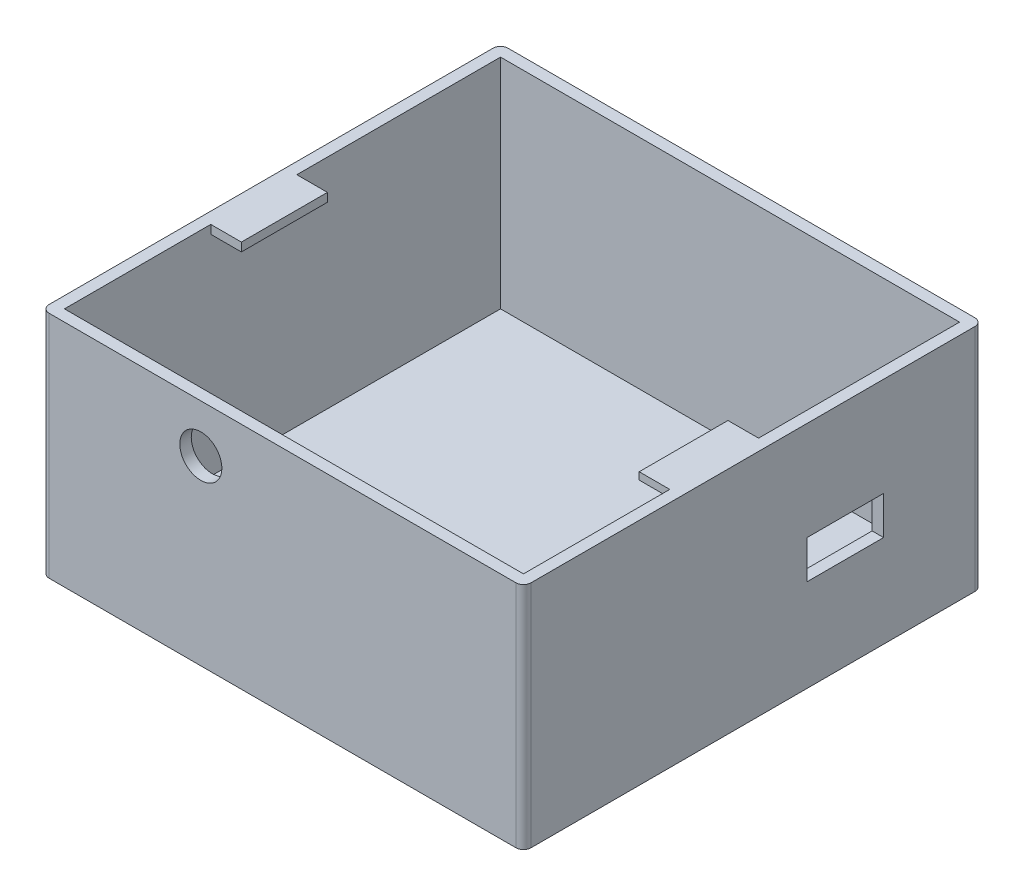
from build123d import *

# Parameters (mm, degrees)
SKETCH1_W               = 63
SKETCH1_H               = 60
BOSS_EXTRUDE1_DEPTH     = 30
SKETCH2_W               = 60
SKETCH2_H               = 57
CUT_EXTRUDE1_DEPTH      = 44
FILLET5_R               = 1
FILLET6_R               = 1
SKETCH4_W               = 11.2479448
SKETCH4_H               = 1.120832932
BOSS_EXTRUDE2_DEPTH     = 4
SKETCH7_W               = 11.602367515
SKETCH7_H               = 0.946433532
BOSS_EXTRUDE3_DEPTH     = 4
SKETCH13_W              = 60
SKETCH13_H              = 1.5
BOSS_EXTRUDE4_DEPTH     = 52
SKETCH8_R               = 2.75
CUT_EXTRUDE2_DEPTH      = 15
CUT_EXTRUDE2_DEPTH_BACK = 20
SKETCH18_W              = 10
SKETCH18_H              = 5
CUT_EXTRUDE4_DEPTH      = 15


with BuildPart() as part:
    # Sketch1 → Boss-Extrude1 (new body)
    with BuildSketch(Plane(origin=(0, 0, 0), x_dir=(1, 0, 0), z_dir=(0, 1, 0))):
        with Locations((8.284946237, -2.70609319)):
            Rectangle(SKETCH1_W, SKETCH1_H)
    extrude(amount=BOSS_EXTRUDE1_DEPTH)

    # Sketch2 → Cut-Extrude1 (cut)
    with BuildSketch(Plane(origin=(0, 0, 0), x_dir=(1, 0, 0), z_dir=(0, 1, 0))):
        with Locations((8.284946237, -2.70609319)):
            Rectangle(SKETCH2_W, SKETCH2_H)
    extrude(amount=CUT_EXTRUDE1_DEPTH, mode=Mode.SUBTRACT)

    # Fillet5
    fillet5_edges = [part.edges().sort_by_distance(p)[0] for p in [
        (39.784946237, 15, -27.29390681),
    ]]
    fillet(fillet5_edges, radius=FILLET5_R)

    # Fillet6
    fillet6_edges = [part.edges().sort_by_distance(p)[0] for p in [
        (-23.215053763, 15, -27.29390681),
        (39.784946237, 15, 32.70609319),
        (-23.215053763, 15, 32.70609319),
    ]]
    fillet(fillet6_edges, radius=FILLET6_R)

    # Sketch4 → Boss-Extrude2 (add)
    with BuildSketch(Plane(origin=(-21.715053763, 0, 0), x_dir=(0, 0, -1), z_dir=(1, 0, 0))):
        with Locations((-6.456507936, 29.439583534)):
            Rectangle(SKETCH4_W, SKETCH4_H)
    extrude(amount=BOSS_EXTRUDE2_DEPTH)

    # Sketch7 → Boss-Extrude3 (add)
    with BuildSketch(Plane.ZY.offset(-38.284946237)):
        with Locations((6.279296579, 29.526783234)):
            Rectangle(SKETCH7_W, SKETCH7_H)
    extrude(amount=BOSS_EXTRUDE3_DEPTH)

    # Sketch13 → Boss-Extrude4 (add)
    with BuildSketch(Plane.XY.offset(-25.79390681)):
        with Locations((8.284946237, 0.75)):
            Rectangle(SKETCH13_W, SKETCH13_H)
    extrude(amount=BOSS_EXTRUDE4_DEPTH)

    # Sketch8 → Cut-Extrude2 (cut, two sides)
    with BuildSketch(Plane.XY.offset(32.70609319)) as cut_extrude2_sk:
        with Locations((-2.391644106, 23.745075348)):
            Circle(SKETCH8_R)
    extrude(amount=CUT_EXTRUDE2_DEPTH, mode=Mode.SUBTRACT)
    extrude(cut_extrude2_sk.sketch, amount=-CUT_EXTRUDE2_DEPTH_BACK, mode=Mode.SUBTRACT)

    # Sketch18 → Cut-Extrude4 (cut)
    with BuildSketch(Plane(origin=(39.784946237, 0, 0), x_dir=(0, 0, -1), z_dir=(1, 0, 0))):
        with Locations((9.363418395, 14.577492713)):
            Rectangle(SKETCH18_W, SKETCH18_H)
    extrude(amount=-CUT_EXTRUDE4_DEPTH, mode=Mode.SUBTRACT)


solid = part.part
